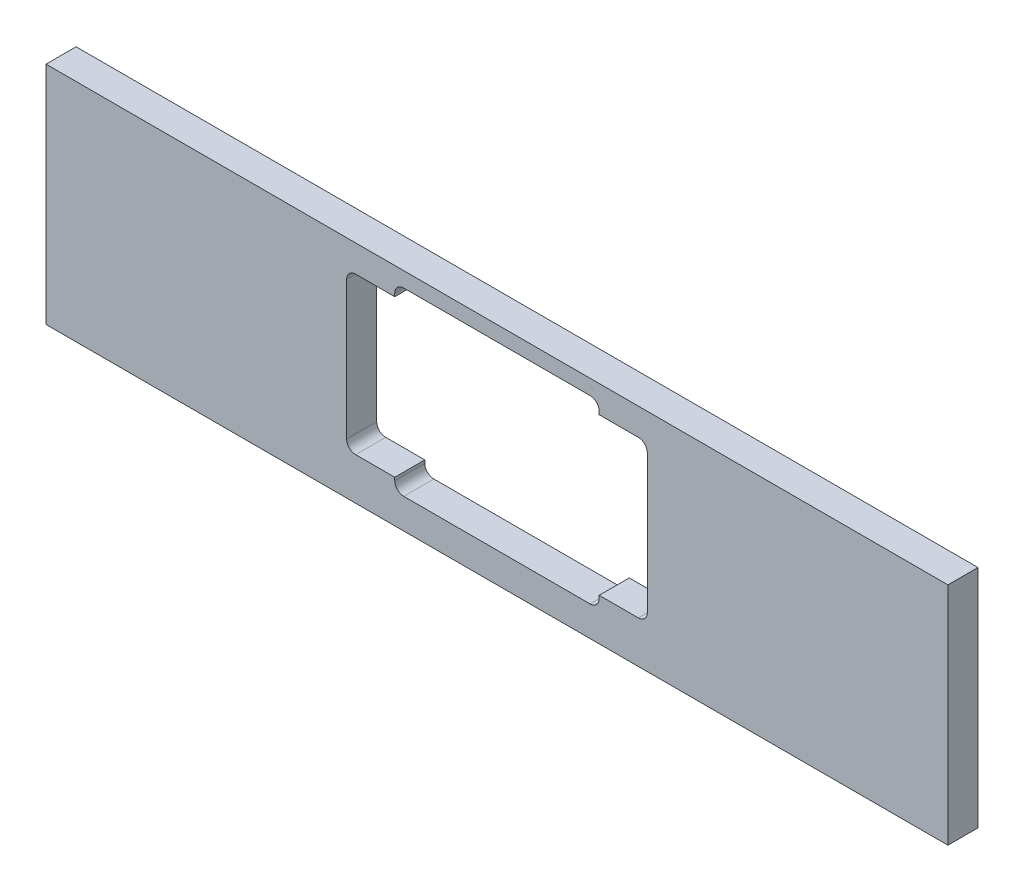
from build123d import *

# Parameters (mm, degrees)
SKIZZE1_W                       = 300
SKIZZE1_H                       = 75
LINEAR_AUSTRAGEN1_DEPTH         = 10
SCHNITT_LINEAR_AUSTRAGEN1_DEPTH = 10
VERRUNDUNG1_R                   = 3


with BuildPart() as part:
    # Skizze1 → Linear austragen1 (new body)
    with BuildSketch(Plane.XY):
        with Locations((0, -112.5)):
            Rectangle(SKIZZE1_W, SKIZZE1_H)
    extrude(amount=LINEAR_AUSTRAGEN1_DEPTH)

    # Skizze2 → Schnitt-Linear austragen1 (cut)
    with BuildSketch(Plane.XY.offset(10)):
        Polygon((-34, -140), (34, -140), (34, -136), (50, -136), (50, -84), (34, -84), (34, -80), (-34, -80), (-34, -84), (-50, -84), (-50, -136), (-34, -136), align=None)
    extrude(amount=-SCHNITT_LINEAR_AUSTRAGEN1_DEPTH, mode=Mode.SUBTRACT)

    # Verrundung1
    verrundung1_edges = [part.edges().sort_by_distance(p)[0] for p in [
        (-34, -140, 5),
        (-50, -136, 5),
        (-50, -84, 5),
        (-34, -80, 5),
        (34, -80, 5),
        (50, -84, 5),
        (50, -136, 5),
        (34, -140, 5),
    ]]
    fillet(verrundung1_edges, radius=VERRUNDUNG1_R)


solid = part.part
